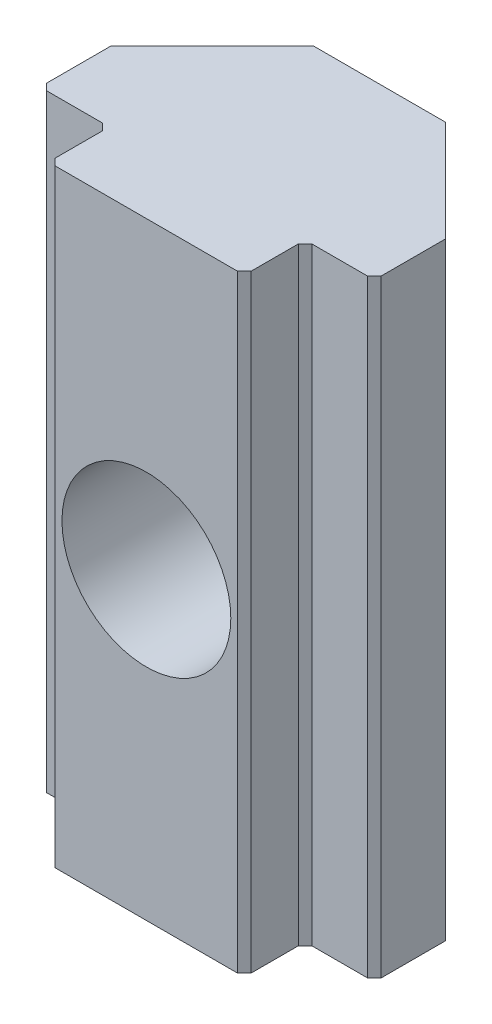
from build123d import *

# Parameters (mm, degrees)
EXTRUDE_1_DEPTH    = 18
CHAMFER_1_SIZE     = 3
CHAMFER_2_SIZE     = 0.2
HOLE_WIZARD_M6_1_D = 5


with BuildPart() as part:
    # 草图1 → 凸台-拉伸1 (new body)
    with BuildSketch(Plane(origin=(0, 0, 0), x_dir=(1, 0, 0), z_dir=(0, 1, 0))):
        Polygon((2.9, -2.55), (4.95, -2.55), (4.95, 2.55), (-4.95, 2.55), (-4.95, -2.55), (-2.9, -2.55), (-2.9, -4.35), (2.9, -4.35), align=None)
    extrude(amount=EXTRUDE_1_DEPTH)

    # 倒角1
    chamfer_1_edges = [part.edges().sort_by_distance(p)[0] for p in [
        (-4.95, 9, -2.55),
        (4.95, 9, -2.55),
    ]]
    chamfer(chamfer_1_edges, length=CHAMFER_1_SIZE)

    # 倒角2
    chamfer_2_edges = [part.edges().sort_by_distance(p)[0] for p in [
        (4.95, 9, 2.55),
        (2.9, 9, 2.55),
        (2.9, 9, 4.35),
        (-2.9, 9, 4.35),
        (-2.9, 9, 2.55),
        (-4.95, 9, 2.55),
    ]]
    chamfer(chamfer_2_edges, length=CHAMFER_2_SIZE)

    # M6 螺纹孔1 (through all)
    with Locations(Plane.XY.offset(4.35)):
        with Locations((0, 9)):
            Hole(HOLE_WIZARD_M6_1_D / 2)


solid = part.part
